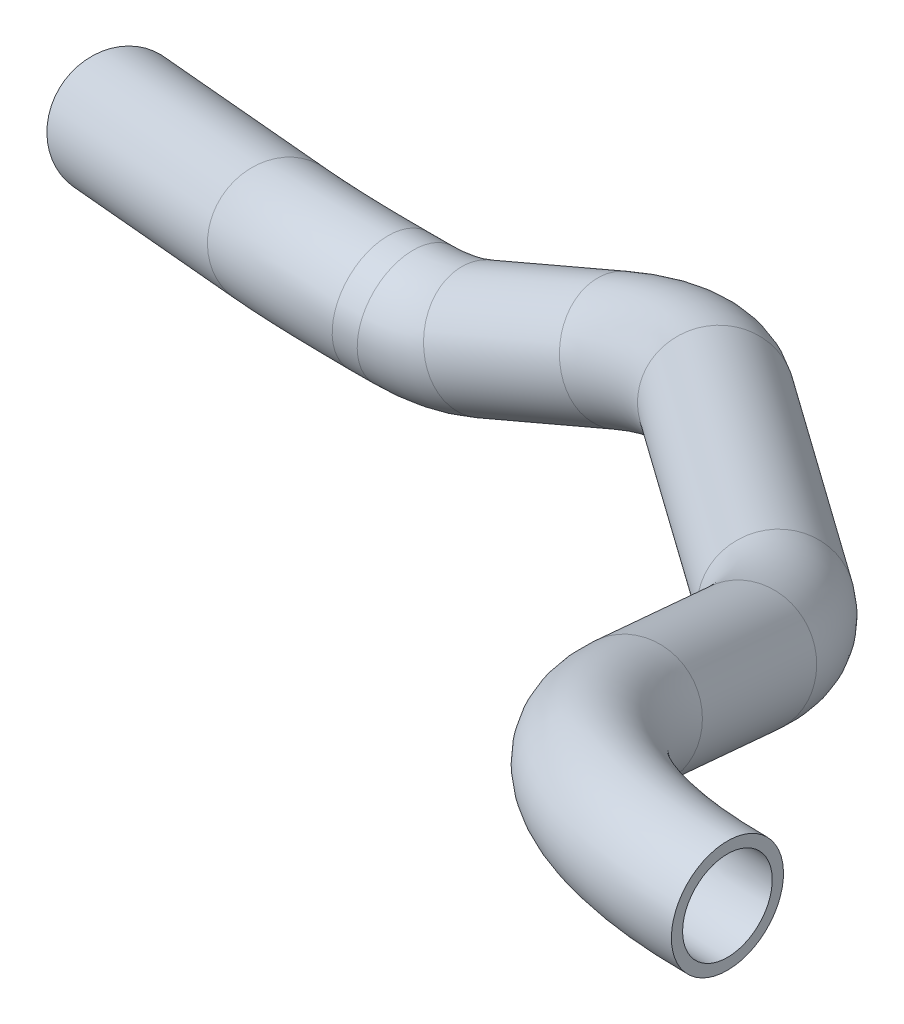
from build123d import *

# Parameters (mm, degrees)
WYCI_GNI_CIE_PO_CIE_CE_CIENKA_CIAN_2_R   = 12.5
WYCI_GNI_CIE_PO_CIE_CE_CIENKA_CIAN_2_R_2 = 10


with BuildPart() as part:
    # Wyciągnięcie po ścieżce-Cienka ścianka1: sweep along a curve in space
    with BuildLine() as wyci_gni_cie_po_cie_ce_cienka_cianka1_path:
        Line((1151.551935215, -307.113467722, 173.439569165), (1129.696364798, -313.458624528, 165.695334052))
        Line((1151.551935215, -307.113467722, 173.439569165), (1185.156220245, -297.357398501, 185.346807417))
        ThreePointArc((1185.156220245, -297.357398501, 185.346807417), (1199.389809123, -294.346258299, 189.021890381), (1214.308973975, -293.326931287, 190.265974378))
        Line((1214.308973975, -293.326931287, 190.265974378), (1219.894910902, -293.326931287, 190.265974378))
        ThreePointArc((1235.622601719, -290.105182218, 190.265974378), (1227.922051201, -292.513217391, 190.265974378), (1219.894910902, -293.326931287, 190.265974378))
        Line((1235.622601719, -290.105182218, 190.265974378), (1265.932911584, -277.143413509, 190.265974378))
        ThreePointArc((1265.932911584, -277.143413509, 190.265974378), (1283.797363065, -269.747937613, 193.458288824), (1299.932584526, -263.553914321, 202.694698616))
        Line((1299.932584526, -263.553914321, 202.694698616), (1372.472988989, -237.060176471, 261.924171563))
        ThreePointArc((1372.472988989, -237.060176471, 261.924171563), (1382.771973534, -232.278738725, 272.935146818), (1389.58101162, -226.802870455, 286.119405336))
        Line((1389.58101162, -226.802870455, 286.119405336), (1403.276379011, -210.822780416, 325.305785456))
        ThreePointArc((1469.875752261, -192.528815146, 370.166250897), (1428.697459915, -197.586110339, 357.764750572), (1403.276379011, -210.822780416, 325.305785456))
    # Wyci_gni_cie po _cie_ce-Cienka _cian 2 (on start of the path) → Wyciągnięcie po ścieżce-Cienka ścianka1 (sweep)
    with BuildSketch(Plane(origin=(1469.875752261, -192.528815146, 370.166250897), x_dir=(0, 0, -1), z_dir=(-1, 0, 0))):
        Circle(WYCI_GNI_CIE_PO_CIE_CE_CIENKA_CIAN_2_R)
        Circle(WYCI_GNI_CIE_PO_CIE_CE_CIENKA_CIAN_2_R_2, mode=Mode.SUBTRACT)
    sweep(path=wyci_gni_cie_po_cie_ce_cienka_cianka1_path.line)


solid = part.part
